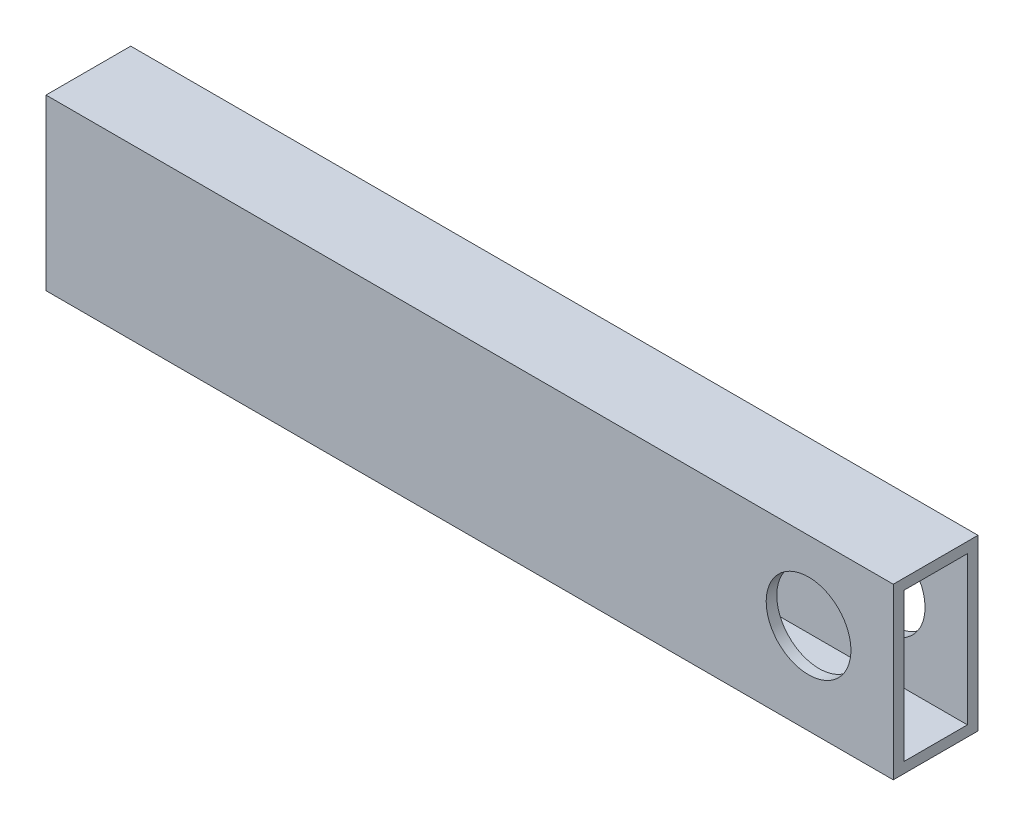
from build123d import *

# Parameters (mm, degrees)
SKETCH1_W               = 25.4
SKETCH1_H               = 50.8
SKETCH1_W_2             = 19.05
SKETCH1_H_2             = 44.45
BOSS_EXTRUDE1_DEPTH     = 304.8
SKETCH2_R               = 12.7
CUT_EXTRUDE1_DEPTH      = 1
CUT_EXTRUDE1_DEPTH_BACK = 26.4
SKETCH3_W               = 50.8
SKETCH3_H               = 55.112369071
CUT_EXTRUDE2_DEPTH      = 159.004


with BuildPart() as part:
    # Sketch1 → Boss-Extrude1 (new body)
    with BuildSketch(Plane(origin=(0, 0, 0), x_dir=(0, 0, -1), z_dir=(1, 0, 0))):
        with Locations((12.7, 25.4)):
            Rectangle(SKETCH1_W, SKETCH1_H)
        with Locations((12.7, 25.4)):
            Rectangle(SKETCH1_W_2, SKETCH1_H_2, mode=Mode.SUBTRACT)
    extrude(amount=BOSS_EXTRUDE1_DEPTH)

    # Sketch2 → Cut-Extrude1 (cut, two sides)
    with BuildSketch(Plane(origin=(0, 0, -25.4), x_dir=(-1, 0, 0), z_dir=(0, 0, -1))) as cut_extrude1_sk:
        with Locations((-279.4, 27.283270028)):
            Circle(SKETCH2_R)
    extrude(amount=CUT_EXTRUDE1_DEPTH, mode=Mode.SUBTRACT)
    extrude(cut_extrude1_sk.sketch, amount=-CUT_EXTRUDE1_DEPTH_BACK, mode=Mode.SUBTRACT)

    # Sketch3 → Cut-Extrude2 (cut)
    with BuildSketch(Plane(origin=(0, 0, -25.4), x_dir=(-1, 0, 0), z_dir=(0, 0, -1))):
        with Locations((-25.4, 23.243815465)):
            Rectangle(SKETCH3_W, SKETCH3_H)
    extrude(amount=-CUT_EXTRUDE2_DEPTH, mode=Mode.SUBTRACT)


solid = part.part
